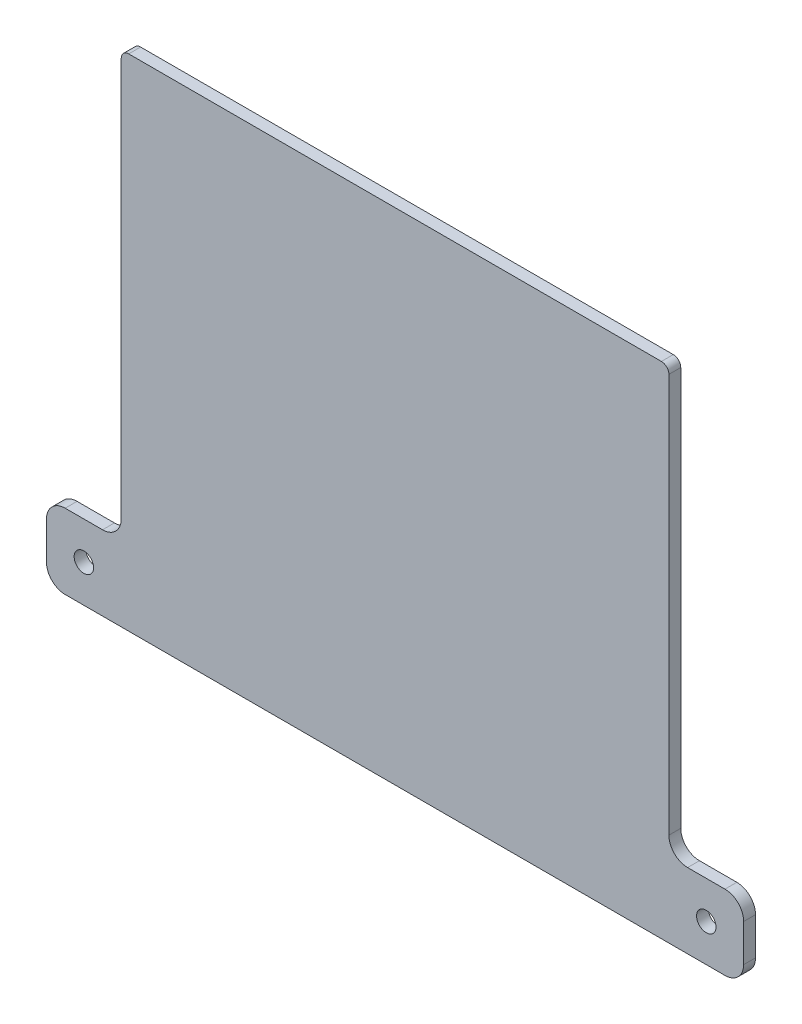
from build123d import *

# Parameters (mm, degrees)
SKETCH1_W           = 20
SKETCH1_H           = 20
SKETCH1_R           = 2.6
SKETCH1_W_2         = 146.5
SKETCH1_H_2         = 133.75
BOSS_EXTRUDE1_DEPTH = 3.175
FILLET2_R           = 5
FILLET3_R           = 2


with BuildPart() as part:
    # Sketch1 → Boss-Extrude1 (new body)
    with BuildSketch(Plane.XY):
        with Locations((-83.25, -56.875)):
            Rectangle(SKETCH1_W, SKETCH1_H)
        with Locations((-83.25, -56.875)):
            Circle(SKETCH1_R, mode=Mode.SUBTRACT)
        Rectangle(SKETCH1_W_2, SKETCH1_H_2)
        with Locations((83.25, -56.875)):
            Rectangle(SKETCH1_W, SKETCH1_H)
        with Locations((83.25, -56.875)):
            Circle(SKETCH1_R, mode=Mode.SUBTRACT)
    extrude(amount=BOSS_EXTRUDE1_DEPTH)

    # Fillet2
    fillet2_edges = [part.edges().sort_by_distance(p)[0] for p in [
        (-73.25, -46.875, 1.5875),
        (73.25, -46.875, 1.5875),
        (93.25, -46.875, 1.5875),
        (93.25, -66.875, 1.5875),
        (-93.25, -66.875, 1.5875),
        (-93.25, -46.875, 1.5875),
    ]]
    fillet(fillet2_edges, radius=FILLET2_R)

    # Fillet3
    fillet3_edges = [part.edges().sort_by_distance(p)[0] for p in [
        (-73.25, 66.875, 1.5875),
        (73.25, 66.875, 1.5875),
    ]]
    fillet(fillet3_edges, radius=FILLET3_R)


solid = part.part
